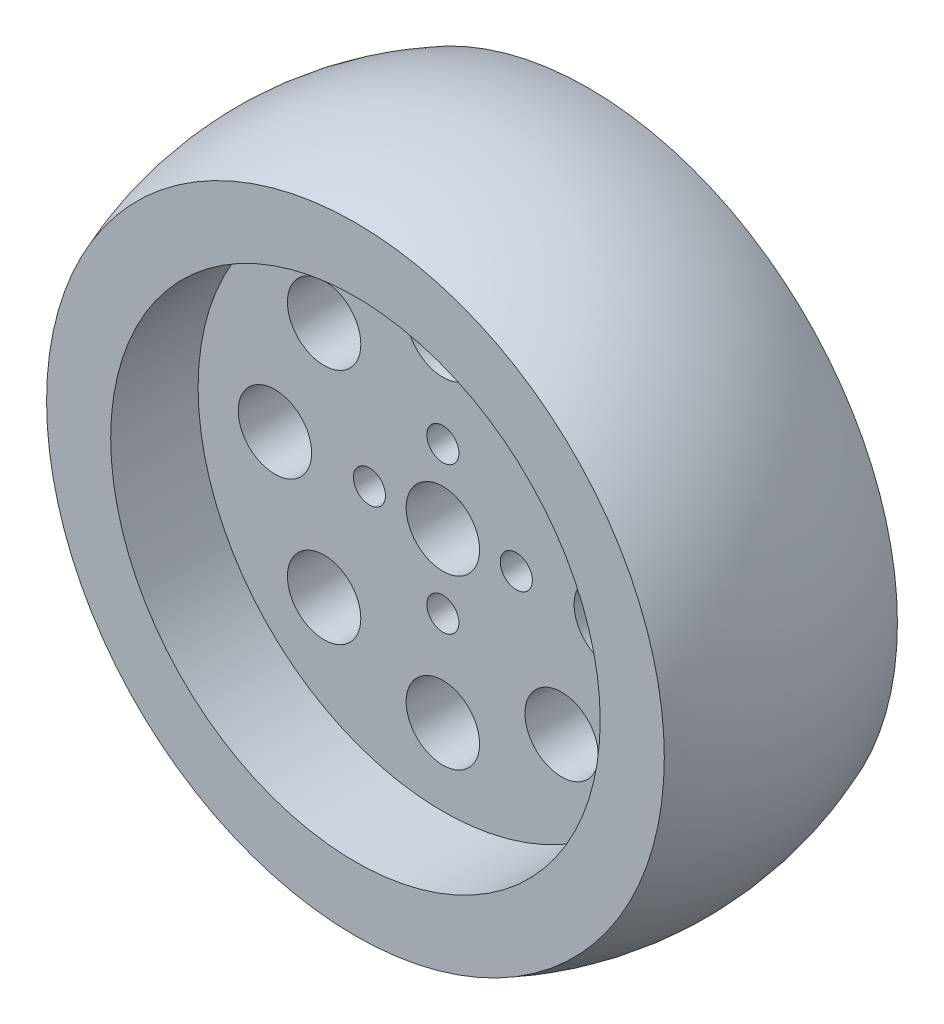
from build123d import *

# Parameters (mm, degrees)
SKETCH1_R          = 31.75
EXTRUDE1_DEPTH     = 21.082
SKETCH2_R          = 26.67
CUT_EXTRUDE1_DEPTH = 7.366
SKETCH3_R          = 26.67
CUT_EXTRUDE2_DEPTH = 7.366
SKETCH5_R          = 33.655
EXTRUDE3_DEPTH     = 2.159
CUT_EXTRUDE3_REACH = 54.967
SKETCH6_R          = 26.67
SKETCH7_R          = 33.655
EXTRUDE4_DEPTH     = 2.159
CUT_EXTRUDE4_REACH = 55.949
SKETCH8_R          = 26.67
SKETCH10_R         = 4
SKETCH10_R_2       = 1.75
CUT_EXTRUDE5_DEPTH = 54.462758337
SKETCH11_R         = 4
CUT_EXTRUDE6_DEPTH = 54.462758337
SKETCH12_R         = 4
CUT_EXTRUDE7_DEPTH = 54.462758337


with BuildPart() as part:
    # Sketch1 → Extrude1 (new body)
    with BuildSketch(Plane.XY):
        Circle(SKETCH1_R)
    extrude(amount=-EXTRUDE1_DEPTH)

    # Sketch2 → Cut-Extrude1 (cut)
    with BuildSketch(Plane.XY):
        Circle(SKETCH2_R)
    extrude(amount=-CUT_EXTRUDE1_DEPTH, mode=Mode.SUBTRACT)

    # Sketch3 → Cut-Extrude2 (cut)
    with BuildSketch(Plane(origin=(0, 0, -21.082), x_dir=(-1, 0, 0), z_dir=(0, 0, -1))):
        with Locations(Location((0, 0, 0), (0, 0, 180))):
            Circle(SKETCH3_R)
    extrude(amount=-CUT_EXTRUDE2_DEPTH, mode=Mode.SUBTRACT)

    # Sketch5 → Extrude3 (add)
    with BuildSketch(Plane.XY):
        Circle(SKETCH5_R)
    extrude(amount=EXTRUDE3_DEPTH)

    # Sketch6 → Cut-Extrude3 (cut, up to next)
    with BuildSketch(Plane.XY.offset(2.159), mode=Mode.PRIVATE) as cut_extrude3_sk1:
        with Locations(Location((0, 0, 0), (0, 0, 180))):
            Circle(SKETCH6_R)
    cut_extrude3_tool1 = extrude(cut_extrude3_sk1.sketch, amount=-CUT_EXTRUDE3_REACH, mode=Mode.PRIVATE) & part.part
    add(cut_extrude3_tool1.solids().sort_by_distance((0, 0, 2.159))[0], mode=Mode.SUBTRACT)

    # Sketch7 → Extrude4 (add)
    with BuildSketch(Plane(origin=(0, 0, -21.082), x_dir=(-1, 0, 0), z_dir=(0, 0, -1))):
        with Locations(Location((0, 0, 0), (0, 0, 180))):
            Circle(SKETCH7_R)
    extrude(amount=EXTRUDE4_DEPTH)

    # Sketch8 → Cut-Extrude4 (cut, up to next)
    with BuildSketch(Plane(origin=(0, 0, -23.241), x_dir=(-1, 0, 0), z_dir=(0, 0, -1)), mode=Mode.PRIVATE) as cut_extrude4_sk1:
        with Locations(Location((0, 0, 0), (0, 0, 180))):
            Circle(SKETCH8_R)
    cut_extrude4_tool1 = extrude(cut_extrude4_sk1.sketch, amount=-CUT_EXTRUDE4_REACH, mode=Mode.PRIVATE) & part.part
    add(cut_extrude4_tool1.solids().sort_by_distance((0, 0, -23.241))[0], mode=Mode.SUBTRACT)

    # Sweep2: sweep along a curve in space
    with BuildLine() as sweep2_path:
        ThreePointArc((33.655, 0, 2.159), (23.797678721, 23.797678721, 2.159), (0, 33.655, 2.159))
        ThreePointArc((0, 33.655, 2.159), (-23.797678721, 23.797678721, 2.159), (-33.655, 0, 2.159))
        ThreePointArc((-33.655, 0, 2.159), (-23.797678721, -23.797678721, 2.159), (0, -33.655, 2.159))
        ThreePointArc((0, -33.655, 2.159), (23.797678721, -23.797678721, 2.159), (33.655, 0, 2.159))
    # 3DSketch2 → Sweep2 (sweep)
    with BuildSketch(Plane(origin=(0, 33.655, 2.159), x_dir=(-8.931812198350224e-14, -0.9285876208505301, -0.37111323124236906), z_dir=(1, 0, 0))):
        with BuildLine():
            Line((0, 0), (0.801233466, 2.004820673))
            Line((0.801233466, 2.004820673), (2.570192884, 1.297849968))
            Line((2.570192884, 1.297849968), (10.394002025, 20.874334191))
            Line((10.394002025, 20.874334191), (8.625042607, 21.581304896))
            Line((8.625042607, 21.581304896), (9.426276074, 23.58612557))
            ThreePointArc((9.426276074, 23.58612557), (2.443828834, 12.7), (0, 0))
        make_face()
    sweep(path=sweep2_path.line)

    # Sketch10 → Cut-Extrude5 (cut, through all)
    with BuildSketch(Plane.XY.offset(-7.366)):
        Circle(SKETCH10_R)
        with Locations((0, 8)):
            Circle(SKETCH10_R_2)
        with Locations((8, 0)):
            Circle(SKETCH10_R_2)
        with Locations((0, -8)):
            Circle(SKETCH10_R_2)
        with Locations((-8, 0)):
            Circle(SKETCH10_R_2)
    extrude(amount=-CUT_EXTRUDE5_DEPTH, mode=Mode.SUBTRACT)

    # Sketch11 → Cut-Extrude6 (cut, through all)
    with BuildSketch(Plane.XY.offset(-7.366)):
        with Locations((0, 18.3)):
            Circle(SKETCH11_R)
        with Locations((18.3, 0)):
            Circle(SKETCH11_R)
        with Locations((0, -18.3)):
            Circle(SKETCH11_R)
        with Locations((-18.3, 0)):
            Circle(SKETCH11_R)
    extrude(amount=-CUT_EXTRUDE6_DEPTH, mode=Mode.SUBTRACT)

    # Sketch12 → Cut-Extrude7 (cut, through all)
    with BuildSketch(Plane.XY.offset(-7.366)):
        with Locations((12.940054096, 12.940054096)):
            Circle(SKETCH12_R)
        with Locations((12.940054096, -12.940054096)):
            Circle(SKETCH12_R)
        with Locations((-12.940054096, -12.940054096)):
            Circle(SKETCH12_R)
        with Locations((-12.940054096, 12.940054096)):
            Circle(SKETCH12_R)
    extrude(amount=-CUT_EXTRUDE7_DEPTH, mode=Mode.SUBTRACT)


solid = part.part
